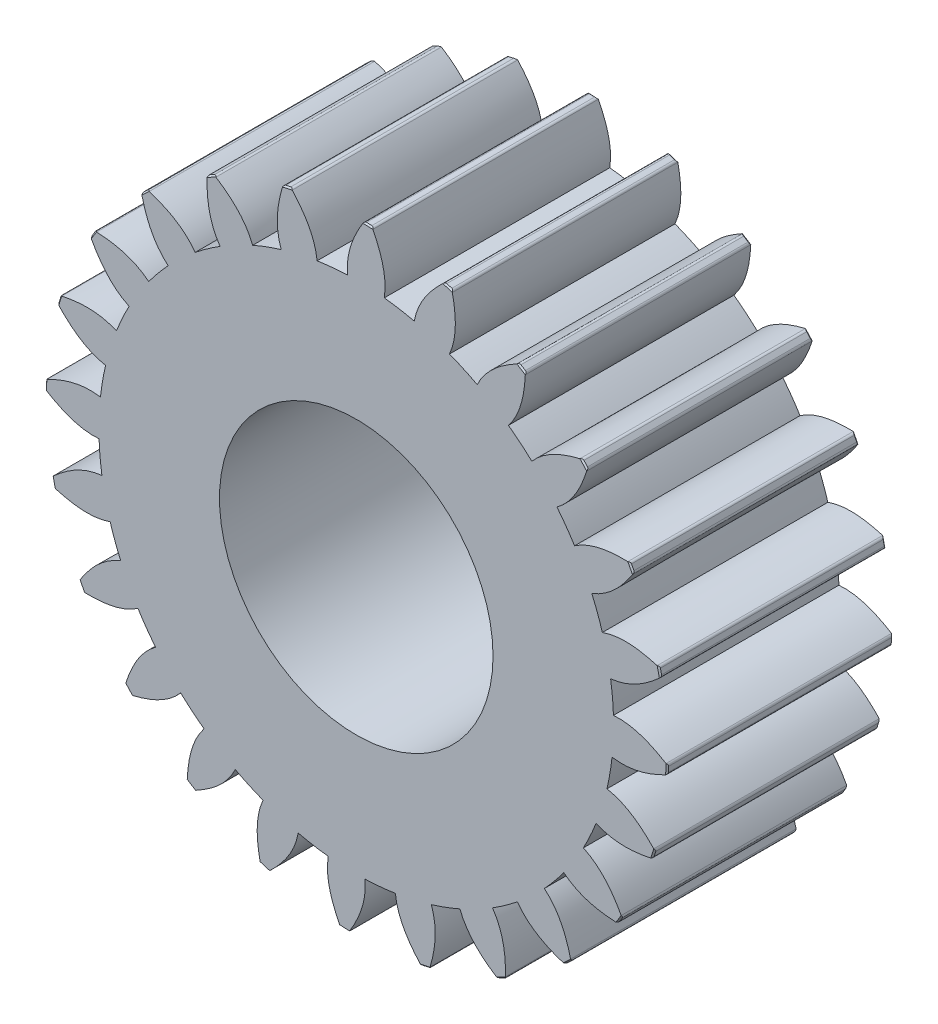
from build123d import *

# Parameters (mm, degrees)
BOSS_EXTRUDE1_DEPTH          = 32.97
CHAMFER1_SIZE                = 0.2
FILLET1_R                    = 0.4
CIRPATTERN1_COUNT            = 24
CHAMFER1_OF_CIRPATTERN1_SIZE = 0.2
FILLET1_OF_CIRPATTERN1_R     = 0.4
SKETCH2_R                    = 20
CUT_EXTRUDE1_DEPTH           = 33.970404896


with BuildPart() as part:
    # Sketch1 → Boss-Extrude1 (new body)
    with BuildSketch(Plane.XY):
        with BuildLine():
            add(Edge.make_bspline(
                [(-11.41279663, 37.68472765), (-11.49404584, 38.19383837), (-11.657505255, 40.23579115), (-11.249301444, 42.437908064), (-10.770402912, 44.068439307), (-10.724973556, 44.217925576)],
                knots=[0, 0, 0, 0, 0.062637346, 0.250140302, 0.269135783, 0.269135783, 0.269135783, 0.269135783], degree=3))
            add(Edge.make_bspline(
                [(-10.98000327, 35.987222082), (-11.180575102, 36.548501949), (-11.321910348, 37.115230664), (-11.41279663, 37.68472765)],
                knots=[-0.070066841, -0.070066841, -0.070066841, -0.070066841, 0, 0, 0, 0], degree=3))
            ThreePointArc((-10.98000327, 35.987222082), (8.37263913, -36.681596735), (-5.722215309, 37.187321454))
            add(Edge.make_bspline(
                [(-5.722215309, 37.187321454), (-5.841214249, 38.309911901), (-6.610756722, 40.838677659), (-8.2785274, 43.115992744), (-9.417480744, 44.377246178), (-9.523272651, 44.492215926)],
                knots=[-0.070066841, -0.070066841, -0.070066841, -0.070066841, 0.062637346, 0.250140302, 0.269135786, 0.269135786, 0.269135786, 0.269135786], degree=3))
            ThreePointArc((-9.523272651, 44.492215926), (-10.125051971, 44.359140237), (-10.724973556, 44.217925576))
        make_face()
    boss_extrude1 = extrude(amount=BOSS_EXTRUDE1_DEPTH)

    # Chamfer1
    chamfer1_edges = [part.edges().sort_by_distance(p)[0] for p in [
        (-10.125051971, 44.359140237, 32.97),
        (-10.125051971, 44.359140237, 0),
    ]]
    chamfer(chamfer1_edges, length=CHAMFER1_SIZE)

    # Fillet1
    fillet1_edges = [part.edges().sort_by_distance(p)[0] for p in [
        (-9.523272651, 44.492215926, 16.485),
        (-10.724973556, 44.217925576, 16.485),
    ]]
    fillet(fillet1_edges, radius=FILLET1_R)

    # CirPattern1: Boss-Extrude1 ×24 about axis
    cirpattern1_axis = Axis((0, 0, 32.97), (0, 0, 1))
    for i in range(1, CIRPATTERN1_COUNT):
        add(boss_extrude1.rotate(cirpattern1_axis, i * 360 / CIRPATTERN1_COUNT))

    # Chamfer1 of CirPattern1
    chamfer1_of_cirpattern1_edges = [part.edges().sort_by_distance(p)[0] for p in [
        (-21.261039509, 40.227082904, 32.97),
        (-21.261039509, 40.227082904, 0),
        (-30.94812234, 33.35361635, 32.97),
        (-30.94812234, 33.35361635, 0),
        (-38.526141778, 24.207155961, 32.97),
        (-38.526141778, 24.207155961, 0),
        (-43.478668321, 13.411017897, 32.97),
        (-43.478668321, 13.411017897, 0),
        (-45.46819547, 1.700941127, 32.97),
        (-45.46819547, 1.700941127, 0),
        (-44.359140237, -10.125051971, 32.97),
        (-44.359140237, -10.125051971, 0),
        (-40.227082904, -21.261039509, 32.97),
        (-40.227082904, -21.261039509, 0),
        (-33.35361635, -30.94812234, 32.97),
        (-33.35361635, -30.94812234, 0),
        (-24.207155961, -38.526141778, 32.97),
        (-24.207155961, -38.526141778, 0),
        (-13.411017897, -43.478668321, 32.97),
        (-13.411017897, -43.478668321, 0),
        (-1.700941127, -45.46819547, 32.97),
        (-1.700941127, -45.46819547, 0),
        (10.125051971, -44.359140237, 32.97),
        (10.125051971, -44.359140237, 0),
        (21.261039509, -40.227082904, 32.97),
        (21.261039509, -40.227082904, 0),
        (30.94812234, -33.35361635, 32.97),
        (30.94812234, -33.35361635, 0),
        (38.526141778, -24.207155961, 32.97),
        (38.526141778, -24.207155961, 0),
        (43.478668321, -13.411017897, 32.97),
        (43.478668321, -13.411017897, 0),
        (45.46819547, -1.700941127, 32.97),
        (45.46819547, -1.700941127, 0),
        (44.359140237, 10.125051971, 32.97),
        (44.359140237, 10.125051971, 0),
        (40.227082904, 21.261039509, 32.97),
        (40.227082904, 21.261039509, 0),
        (33.35361635, 30.94812234, 32.97),
        (33.35361635, 30.94812234, 0),
        (24.207155961, 38.526141778, 32.97),
        (24.207155961, 38.526141778, 0),
        (13.411017897, 43.478668321, 32.97),
        (13.411017897, 43.478668321, 0),
        (1.700941127, 45.46819547, 32.97),
        (1.700941127, 45.46819547, 0),
    ]]
    chamfer(chamfer1_of_cirpattern1_edges, length=CHAMFER1_OF_CIRPATTERN1_SIZE)

    # Fillet1 of CirPattern1
    fillet1_of_cirpattern1_edges = [part.edges().sort_by_distance(p)[0] for p in [
        (-20.714207845, 40.511376098, 16.485),
        (-21.803970218, 39.935408884, 16.485),
        (-30.493504006, 33.769752937, 16.485),
        (-31.397062342, 32.931360073, 16.485),
        (-38.194718262, 24.726776921, 16.485),
        (-38.850496554, 23.683093495, 16.485),
        (-43.293025588, 13.99871192, 16.485),
        (-43.656333629, 12.820863233, 16.485),
        (-45.440984766, 2.316657836, 16.485),
        (-45.487063713, 1.08491233, 16.485),
        (-44.492215926, -9.523272651, 16.485),
        (-44.217925576, -10.724973556, 16.485),
        (-40.511376098, -20.714207845, 16.485),
        (-39.935408884, -21.803970218, 16.485),
        (-33.769752937, -30.493504006, 16.485),
        (-32.931360073, -31.397062342, 16.485),
        (-24.726776921, -38.194718262, 16.485),
        (-23.683093495, -38.850496554, 16.485),
        (-13.99871192, -43.293025588, 16.485),
        (-12.820863233, -43.656333629, 16.485),
        (-2.316657836, -45.440984766, 16.485),
        (-1.08491233, -45.487063713, 16.485),
        (9.523272651, -44.492215926, 16.485),
        (10.724973556, -44.217925576, 16.485),
        (20.714207845, -40.511376098, 16.485),
        (21.803970218, -39.935408884, 16.485),
        (30.493504006, -33.769752937, 16.485),
        (31.397062342, -32.931360073, 16.485),
        (38.194718262, -24.726776921, 16.485),
        (38.850496554, -23.683093495, 16.485),
        (43.293025588, -13.99871192, 16.485),
        (43.656333629, -12.820863233, 16.485),
        (45.440984766, -2.316657836, 16.485),
        (45.487063713, -1.08491233, 16.485),
        (44.492215926, 9.523272651, 16.485),
        (44.217925576, 10.724973556, 16.485),
        (40.511376098, 20.714207845, 16.485),
        (39.935408884, 21.803970218, 16.485),
        (33.769752937, 30.493504006, 16.485),
        (32.931360073, 31.397062342, 16.485),
        (24.726776921, 38.194718262, 16.485),
        (23.683093495, 38.850496554, 16.485),
        (13.99871192, 43.293025588, 16.485),
        (12.820863233, 43.656333629, 16.485),
        (2.316657836, 45.440984766, 16.485),
        (1.08491233, 45.487063713, 16.485),
    ]]
    fillet(fillet1_of_cirpattern1_edges, radius=FILLET1_OF_CIRPATTERN1_R)

    # Sketch2 → Cut-Extrude1 (cut, through all)
    with BuildSketch(Plane.XY.offset(32.97)):
        Circle(SKETCH2_R)
    extrude(amount=-CUT_EXTRUDE1_DEPTH, mode=Mode.SUBTRACT)


solid = part.part
